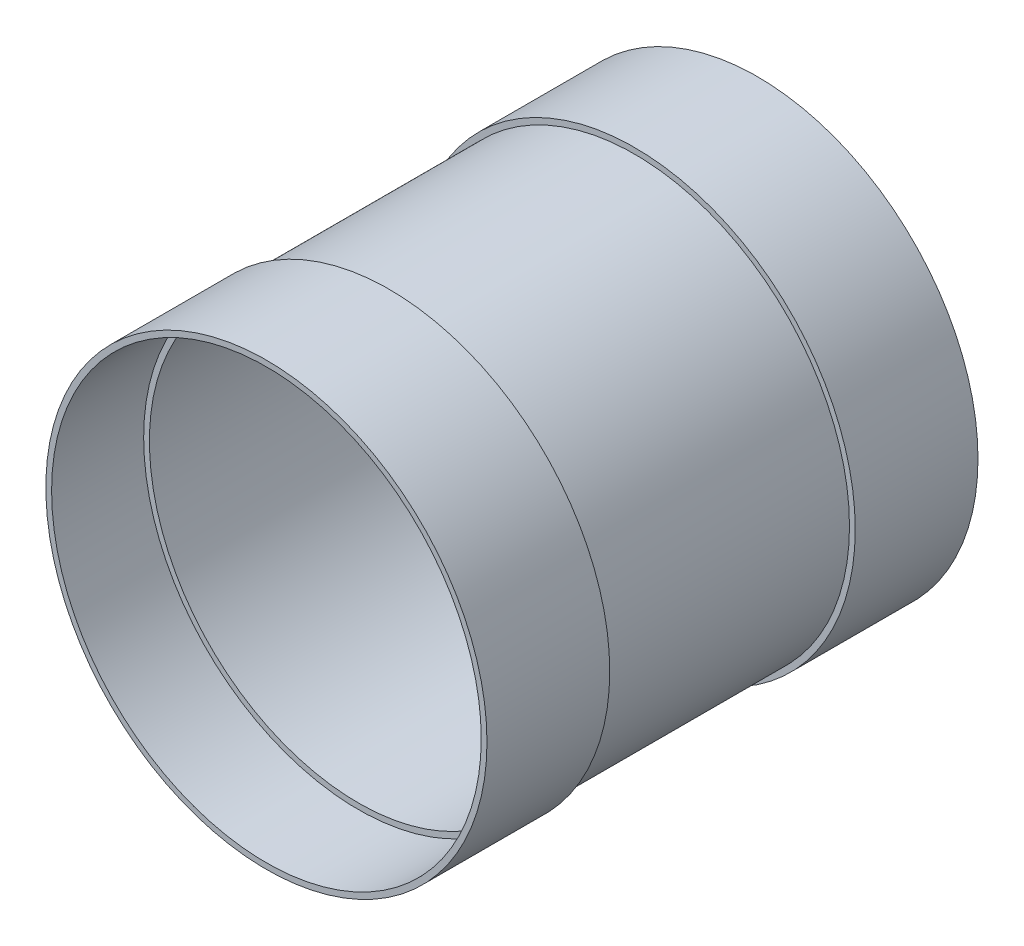
from build123d import *

# Parameters (mm, degrees)
SKETCH2_W = 101.6
SKETCH2_H = 4.7625
SKETCH3_W = 254
SKETCH3_H = 4.7625


with BuildPart() as part:
    # Sketch2 → Revolve1 (revolve)
    with BuildSketch(Plane(origin=(0, 0, 0), x_dir=(0, 0, -1), z_dir=(1, 0, 0)), mode=Mode.PRIVATE) as revolve1_sk:
        with Locations((-152.4, 180.18125)):
            Rectangle(SKETCH2_W, SKETCH2_H)
        with Locations((152.4, 180.18125)):
            Rectangle(SKETCH2_W, SKETCH2_H)
    revolve(revolve1_sk.sketch.rotate(Axis((0, 0, 62.594581749), (0, 0, -1)), 90), axis=Axis((0, 0, 62.594581749), (0, 0, -1)))  # turned: the seam where the file's is


with BuildPart() as body_2:
    # Sketch3 → Revolve2 (revolve)
    with BuildSketch(Plane(origin=(0, 0, 0), x_dir=(0, 0, -1), z_dir=(1, 0, 0)), mode=Mode.PRIVATE) as revolve2_sk:
        with Locations((0, 175.41875)):
            Rectangle(SKETCH3_W, SKETCH3_H)
    revolve(revolve2_sk.sketch.rotate(Axis((0, 0, 0), (0, 0, -1)), 90), axis=Axis((0, 0, 0), (0, 0, -1)))  # turned: the seam where the file's is


solid = Compound([part.part, body_2.part])
